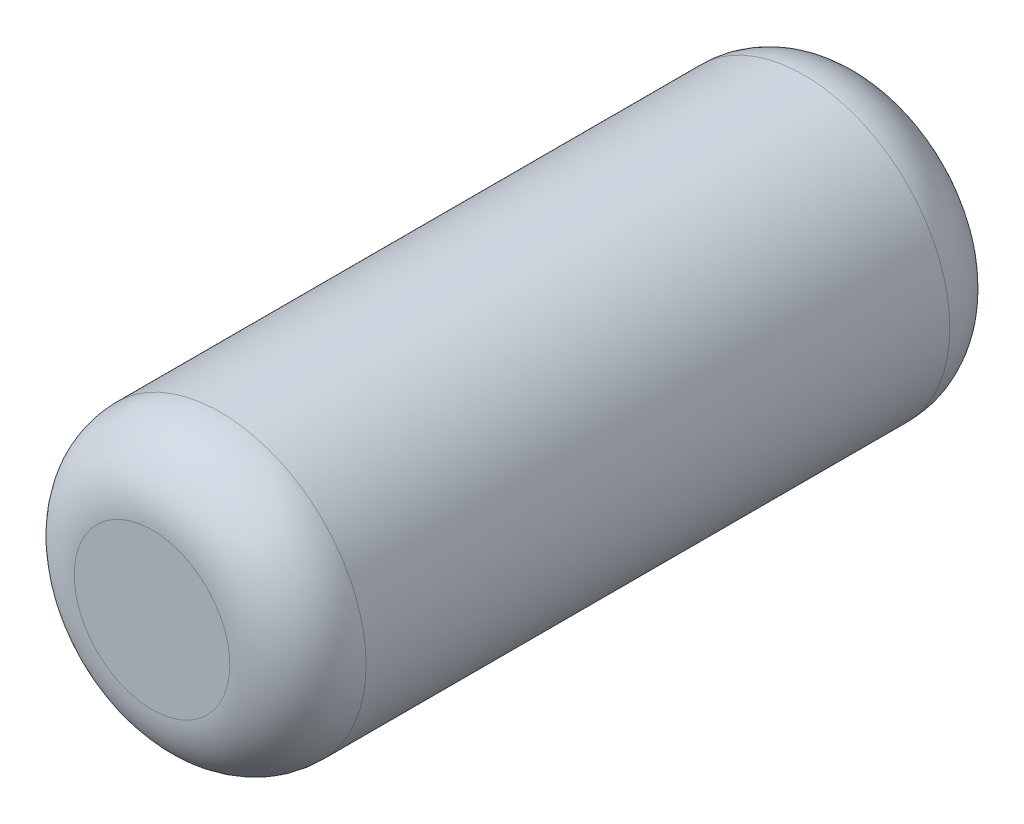
from build123d import *

# Parameters (mm, degrees)
SKETCH1_R           = 0.75
BOSS_EXTRUDE1_DEPTH = 1.85
FILLET1_R           = 0.35


with BuildPart() as part:
    # Sketch1 → Boss-Extrude1 (new body, symmetric)
    with BuildSketch(Plane.XY):
        Circle(SKETCH1_R)
    extrude(amount=BOSS_EXTRUDE1_DEPTH, both=True)

    # Fillet1
    fillet1_edges = [part.edges().sort_by_distance(p)[0] for p in [
        (-0.75, 0, -1.85),
        (-0.75, 0, 1.85),
    ]]
    fillet(fillet1_edges, radius=FILLET1_R)


solid = part.part
